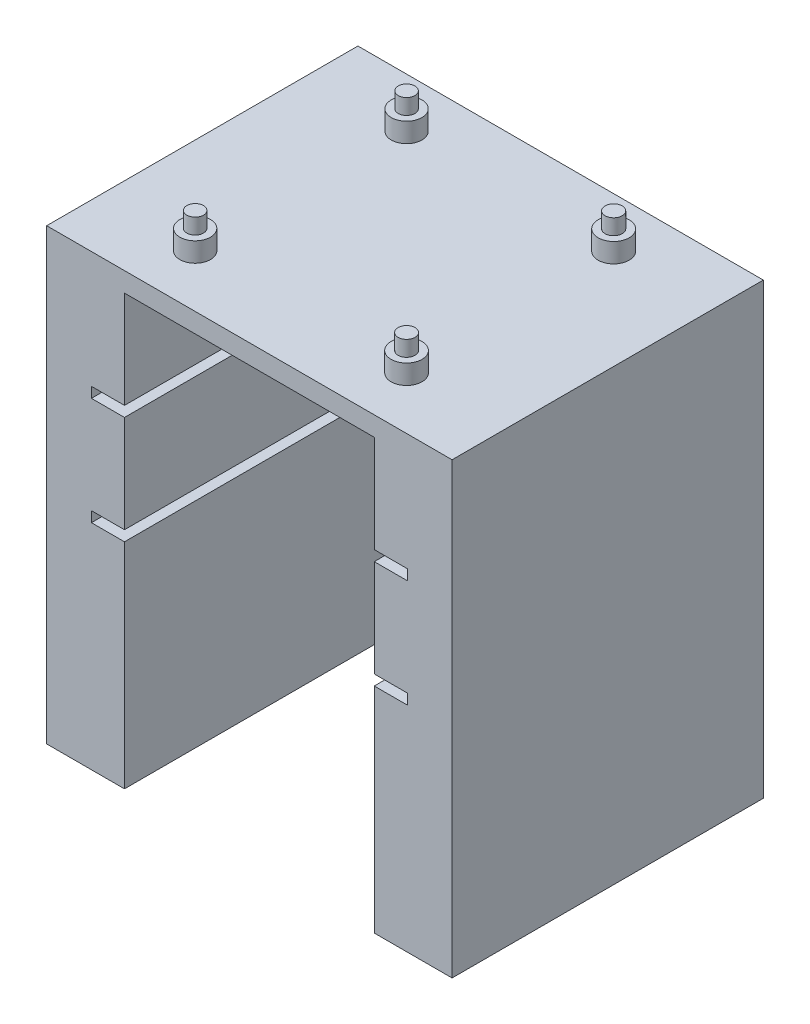
from build123d import *

# Parameters (mm, degrees)
BOSS_EXTRUDE1_DEPTH = 50.8
SKETCH3_R           = 2.500488375
SKETCH3_R_2         = 1.357488375
SKETCH3_R_3         = 2.499609862
SKETCH3_R_4         = 2.52658695
SKETCH3_R_5         = 2.538600877
BOSS_EXTRUDE2_DEPTH = 3.175
BOSS_EXTRUDE3_START = 3.175
SKETCH3_3_R         = 1.357488375
SKETCH3_3_R_2       = 1.356609862
SKETCH3_3_R_3       = 1.38358695
SKETCH3_3_R_4       = 1.395600877
BOSS_EXTRUDE3_DEPTH = 2.54
SKETCH4_R           = 2.5
CUT_EXTRUDE1_DEPTH  = 10


with BuildPart() as part:
    # Sketch1 → Boss-Extrude1 (new body)
    with BuildSketch(Plane.XY):
        Polygon((12.7, 70.0786), (12.7, 54.2036), (7.3025, 54.2036), (7.3025, 52.5018), (12.7, 52.5018), (12.7, 36.6268), (7.3025, 36.6268), (7.3025, 34.925), (12.7, 34.925), (12.7, 0), (0, 0), (0, 73.2536), (66.167, 73.2536), (66.167, 0), (53.467, 0), (53.467, 34.925), (58.8645, 34.925), (58.8645, 36.6268), (53.467, 36.6268), (53.467, 52.5018), (58.8645, 52.5018), (58.8645, 54.2036), (53.467, 54.2036), (53.467, 70.0786), align=None)
    extrude(amount=BOSS_EXTRUDE1_DEPTH)

    # Sketch3 → Boss-Extrude2 (add)
    with BuildSketch(Plane(origin=(0, 73.2536, 0), x_dir=(1, 0, 0), z_dir=(0, 1, 0))):
        with Locations(Location((16.012534946, -8.068344252, 0), (0, 0, 90))):
            Circle(SKETCH3_R)
        with Locations((16.012534946, -8.068344252)):
            Circle(SKETCH3_R_2, mode=Mode.SUBTRACT)
        with Locations((16.012534946, -8.068344252)):
            Circle(SKETCH3_R_2)
        with Locations(Location((15.66334422, -42.22825299, 0), (0, 0, 90))):
            Circle(SKETCH3_R_3)
        with Locations(Location((50.174167917, -42.233596828, 0), (0, 0, 90))):
            Circle(SKETCH3_R_4)
        with Locations(Location((49.881189528, -8.139195897, 0), (0, 0, 90))):
            Circle(SKETCH3_R_5)
    extrude(amount=BOSS_EXTRUDE2_DEPTH)

    # Sketch3_3 → Boss-Extrude3 (add)
    with BuildSketch(Plane(origin=(0, 73.2536, 0), x_dir=(1, 0, 0), z_dir=(0, 1, 0)).offset(BOSS_EXTRUDE3_START)):
        with Locations(Location((16.012534946, -8.068344252, 0), (0, 0, 270))):
            Circle(SKETCH3_3_R)
        with Locations(Location((15.66334422, -42.22825299, 0), (0, 0, 270))):
            Circle(SKETCH3_3_R_2)
        with Locations(Location((50.174167917, -42.233596828, 0), (0, 0, 270))):
            Circle(SKETCH3_3_R_3)
        with Locations(Location((49.881189528, -8.139195897, 0), (0, 0, 270))):
            Circle(SKETCH3_3_R_4)
    extrude(amount=BOSS_EXTRUDE3_DEPTH)

    # Sketch4 → Cut-Extrude1 (cut)
    with BuildSketch(Plane.XZ):
        with Locations(Location((6.35, 38.1, 0), (0, 0, 270))):
            Circle(SKETCH4_R)
        with Locations(Location((6.35, 12.7, 0), (0, 0, 270))):
            Circle(SKETCH4_R)
        with Locations(Location((59.817, 38.1, 0), (0, 0, 270))):
            Circle(SKETCH4_R)
        with Locations(Location((59.817, 12.7, 0), (0, 0, 270))):
            Circle(SKETCH4_R)
    extrude(amount=-CUT_EXTRUDE1_DEPTH, mode=Mode.SUBTRACT)


solid = part.part
